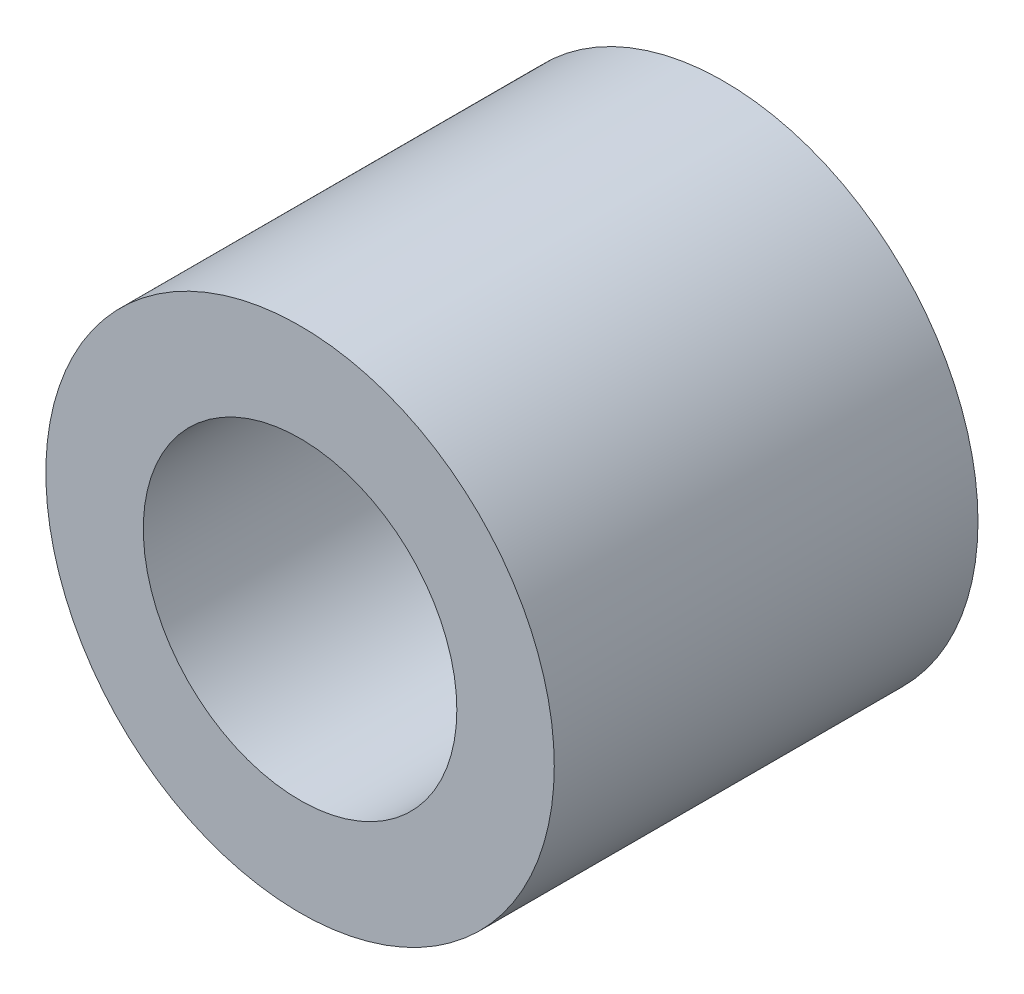
from build123d import *

# Parameters (mm, degrees)
ESQUISSE1_R        = 3
ESQUISSE1_R_2      = 1.85
BOSS_EXTRU_1_DEPTH = 5


with BuildPart() as part:
    # Esquisse1 → Boss.-Extru.1 (new body)
    with BuildSketch(Plane.XY):
        Circle(ESQUISSE1_R)
        Circle(ESQUISSE1_R_2, mode=Mode.SUBTRACT)
    extrude(amount=BOSS_EXTRU_1_DEPTH)


solid = part.part
